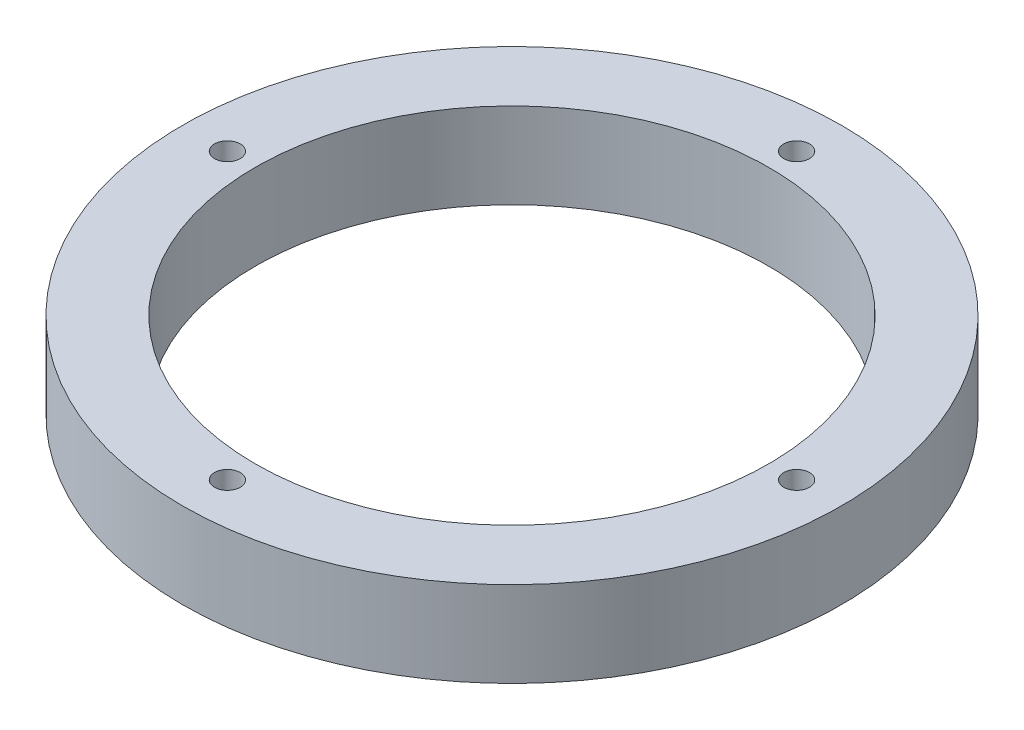
from build123d import *

# Parameters (mm, degrees)
SKETCH1_R           = 48.895
SKETCH1_R_2         = 38.1
SKETCH1_R_3         = 1.905
BOSS_EXTRUDE1_DEPTH = 12.7


with BuildPart() as part:
    # Sketch1 → Boss-Extrude1 (new body)
    with BuildSketch(Plane(origin=(0, 0, 0), x_dir=(1, 0, 0), z_dir=(0, 1, 0))):
        Circle(SKETCH1_R)
        Circle(SKETCH1_R_2, mode=Mode.SUBTRACT)
        with Locations((0, 42.2275)):
            Circle(SKETCH1_R_3, mode=Mode.SUBTRACT)
        with Locations((42.2275, 0)):
            Circle(SKETCH1_R_3, mode=Mode.SUBTRACT)
        with Locations((0, -42.2275)):
            Circle(SKETCH1_R_3, mode=Mode.SUBTRACT)
        with Locations((-42.2275, 0)):
            Circle(SKETCH1_R_3, mode=Mode.SUBTRACT)
    extrude(amount=BOSS_EXTRUDE1_DEPTH)


solid = part.part
